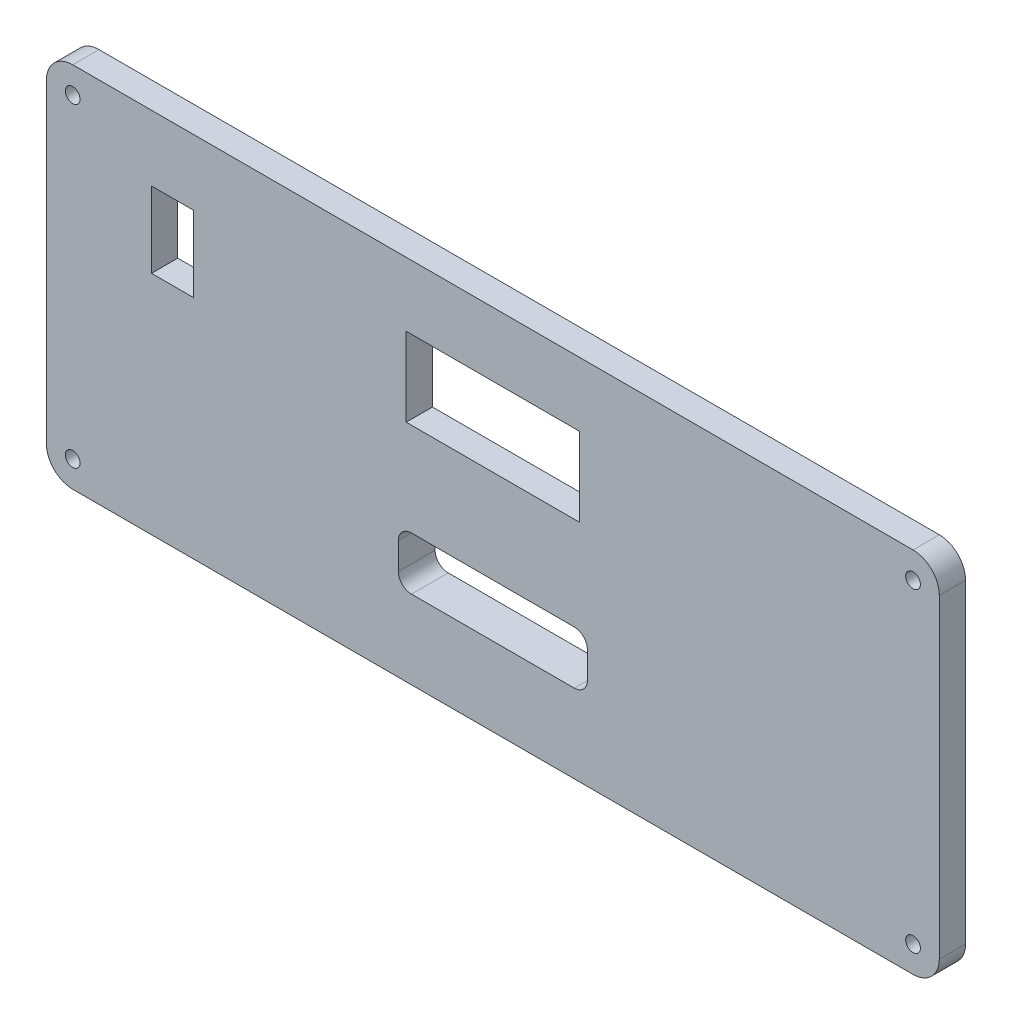
from build123d import *

# Parameters (mm, degrees)
SKETCH1_W           = 170
SKETCH1_H           = 70
BOSS_EXTRUDE1_DEPTH = 5
FILLET2_R           = 5
SKETCH3_R           = 1.4
CUT_EXTRUDE1_DEPTH  = 5
SKETCH5_R           = 1.4
CUT_EXTRUDE2_DEPTH  = 5
CUT_EXTRUDE5_DEPTH  = 5
CUT_EXTRUDE7_DEPTH  = 5
BOSS_EXTRUDE2_DEPTH = 10
CUT_EXTRUDE8_DEPTH  = 10
SKETCH10_W          = 3
SKETCH10_H          = 26
CUT_EXTRUDE9_DEPTH  = 57
FILLET3_R           = 2.5


with BuildPart() as part:
    # Sketch1 → Boss-Extrude1 (new body)
    with BuildSketch(Plane.XY):
        Rectangle(SKETCH1_W, SKETCH1_H)
    extrude(amount=BOSS_EXTRUDE1_DEPTH)

    # Fillet2
    fillet2_edges = [part.edges().sort_by_distance(p)[0] for p in [
        (85, -35, 2.5),
        (-85, -35, 2.5),
        (-85, 35, 2.5),
        (85, 35, 2.5),
    ]]
    fillet(fillet2_edges, radius=FILLET2_R)

    # Sketch3 → Cut-Extrude1 (cut)
    with BuildSketch(Plane.XY):
        with Locations((-80, 30)):
            Circle(SKETCH3_R)
    extrude(amount=CUT_EXTRUDE1_DEPTH, mode=Mode.SUBTRACT)

    # Sketch5 → Cut-Extrude2 (cut)
    with BuildSketch(Plane.XY.offset(5)):
        with Locations((-80, -30)):
            Circle(SKETCH5_R)
        with Locations((80, 30)):
            Circle(SKETCH5_R)
        with Locations((80, -30)):
            Circle(SKETCH5_R)
    extrude(amount=-CUT_EXTRUDE2_DEPTH, mode=Mode.SUBTRACT)

    # Sketch6 → Cut-Extrude5 (cut)
    with BuildSketch(Plane.XY):
        Polygon((0, 7.806871993), (16.5, 7.806871993), (16.5, 22.806871993), (-16.5, 22.806871993), (-16.5, 7.806871993), align=None)
    extrude(amount=CUT_EXTRUDE5_DEPTH, mode=Mode.SUBTRACT)

    # Sketch7 → Cut-Extrude7 (cut)
    with BuildSketch(Plane.XY):
        Polygon((-65, 15.306871993), (-65, 22.506871993), (-57, 22.506871993), (-57, 15.306871993), (-57, 8.106871993), (-65, 8.106871993), align=None)
    extrude(amount=CUT_EXTRUDE7_DEPTH, mode=Mode.SUBTRACT)

    # Sketch8 → Boss-Extrude2 (add)
    with BuildSketch(Plane.XY.offset(5)):
        Polygon((0, -2), (28.5, -2), (28.5, -14.153073617), (28.5, -28), (-28.5, -28), (-28.5, -14.153073617), (-28.5, -2), align=None)
    extrude(amount=-BOSS_EXTRUDE2_DEPTH)

    # Sketch9 → Cut-Extrude8 (cut)
    with BuildSketch(Plane(origin=(0, 0, -5), x_dir=(-1, 0, 0), z_dir=(0, 0, -1))):
        Polygon((18, -20.04), (-18, -20.04), (-18, -15), (-18, -9.96), (18, -9.96), (18, -15), align=None)
    extrude(amount=-CUT_EXTRUDE8_DEPTH, mode=Mode.SUBTRACT)

    # Sketch10 → Cut-Extrude9 (cut)
    with BuildSketch(Plane(origin=(28.5, 0, 0), x_dir=(0, 0, -1), z_dir=(1, 0, 0))):
        with Locations((3.5, -15)):
            Rectangle(SKETCH10_W, SKETCH10_H)
    extrude(amount=-CUT_EXTRUDE9_DEPTH, mode=Mode.SUBTRACT)

    # Fillet3
    fillet3_edges = [part.edges().sort_by_distance(p)[0] for p in [
        (18, -9.96, 1.5),
        (-18, -9.96, 1.5),
        (-18, -20.04, 1.5),
        (18, -20.04, 1.5),
    ]]
    fillet(fillet3_edges, radius=FILLET3_R)


solid = part.part
